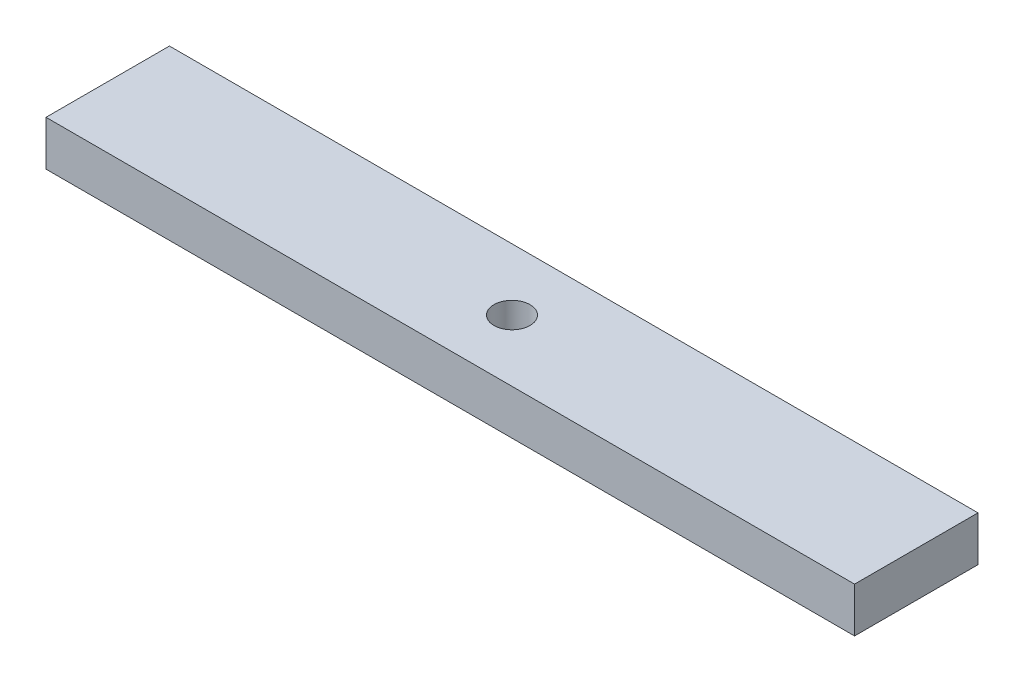
from build123d import *

# Parameters (mm, degrees)
SKETCH1_W           = 114.3
SKETCH1_H           = 17.4498
SKETCH1_R           = 2.5527
BOSS_EXTRUDE1_DEPTH = 6.35


with BuildPart() as part:
    # Sketch1 → Boss-Extrude1 (new body)
    with BuildSketch(Plane(origin=(0, 0, 0), x_dir=(1, 0, 0), z_dir=(0, 1, 0))):
        Rectangle(SKETCH1_W, SKETCH1_H)
        Circle(SKETCH1_R, mode=Mode.SUBTRACT)
    extrude(amount=BOSS_EXTRUDE1_DEPTH)


solid = part.part
